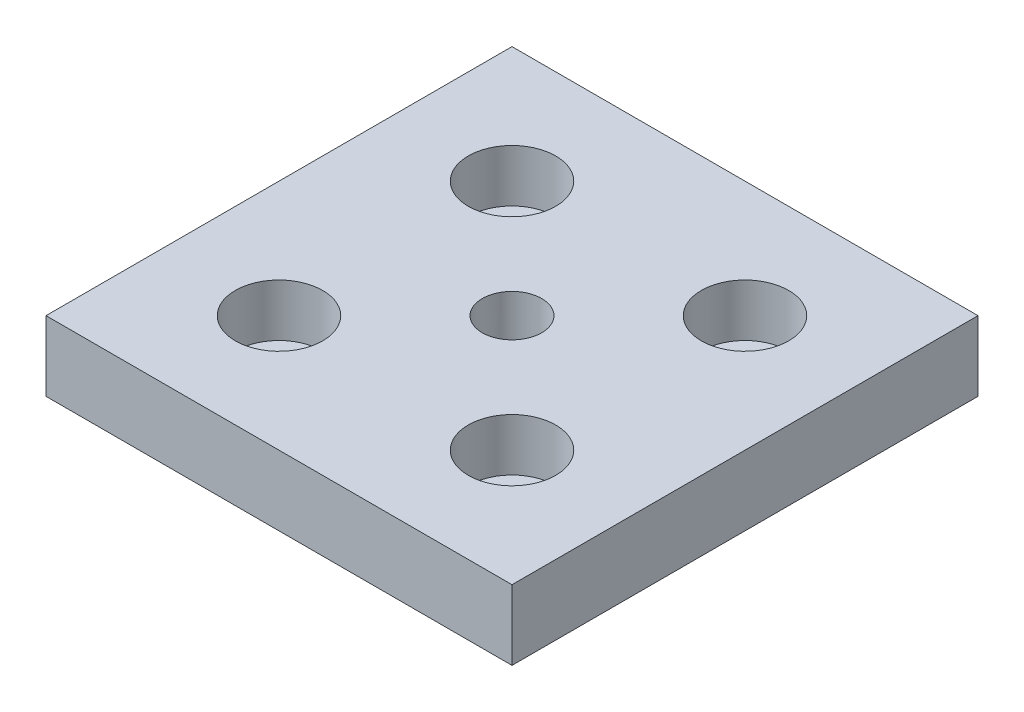
from build123d import *

# Parameters (mm, degrees)
SKETCH_1_W             = 80
SKETCH_1_H             = 80
EXTRUDE_1_DEPTH        = 12
HOLE_WIZARD_M121_D     = 10.2
HOLE_WIZARD_M121_DEPTH = 12
SKETCH_12_R            = 4.5
CUT_EXTRUDE_1_DEPTH    = 13
SKETCH_13_R            = 7.5
CUT_EXTRUDE_2_DEPTH    = 9


with BuildPart() as part:
    # Эскиз1 → Бобышка-Вытянуть1 (new body)
    with BuildSketch(Plane(origin=(0, 0, 0), x_dir=(1, 0, 0), z_dir=(0, 1, 0))):
        Rectangle(SKETCH_1_W, SKETCH_1_H)
    extrude(amount=EXTRUDE_1_DEPTH)

    # Отверстие обработанное метчиком M121
    with Locations(Plane(origin=(0, 12, 0), x_dir=(1, 0, 0), z_dir=(0, 1, 0))):
        with Locations((0, 0)):
            Hole(HOLE_WIZARD_M121_D / 2, depth=HOLE_WIZARD_M121_DEPTH)

    # Эскиз12 → Вырез-Вытянуть1 (cut, through all)
    with BuildSketch(Plane(origin=(0, 12, 0), x_dir=(1, 0, 0), z_dir=(0, 1, 0))):
        with Locations(Location((-20, 20, 0), (0, 0, 270))):  # turned: the seam where the file's is
            Circle(SKETCH_12_R)
        with Locations(Location((20, 20, 0), (0, 0, 270))):  # turned: the seam where the file's is
            Circle(SKETCH_12_R)
        with Locations(Location((20, -20, 0), (0, 0, 270))):  # turned: the seam where the file's is
            Circle(SKETCH_12_R)
        with Locations(Location((-20, -20, 0), (0, 0, 270))):  # turned: the seam where the file's is
            Circle(SKETCH_12_R)
    extrude(amount=-CUT_EXTRUDE_1_DEPTH, mode=Mode.SUBTRACT)

    # Эскиз13 → Вырез-Вытянуть2 (cut)
    with BuildSketch(Plane(origin=(0, 12, 0), x_dir=(1, 0, 0), z_dir=(0, 1, 0))):
        with Locations(Location((-20, 20, 0), (0, 0, 270))):  # turned: the seam where the file's is
            Circle(SKETCH_13_R)
        with Locations(Location((20, 20, 0), (0, 0, 270))):  # turned: the seam where the file's is
            Circle(SKETCH_13_R)
        with Locations(Location((20, -20, 0), (0, 0, 270))):  # turned: the seam where the file's is
            Circle(SKETCH_13_R)
        with Locations(Location((-20, -20, 0), (0, 0, 270))):  # turned: the seam where the file's is
            Circle(SKETCH_13_R)
    extrude(amount=-CUT_EXTRUDE_2_DEPTH, mode=Mode.SUBTRACT)


solid = part.part
